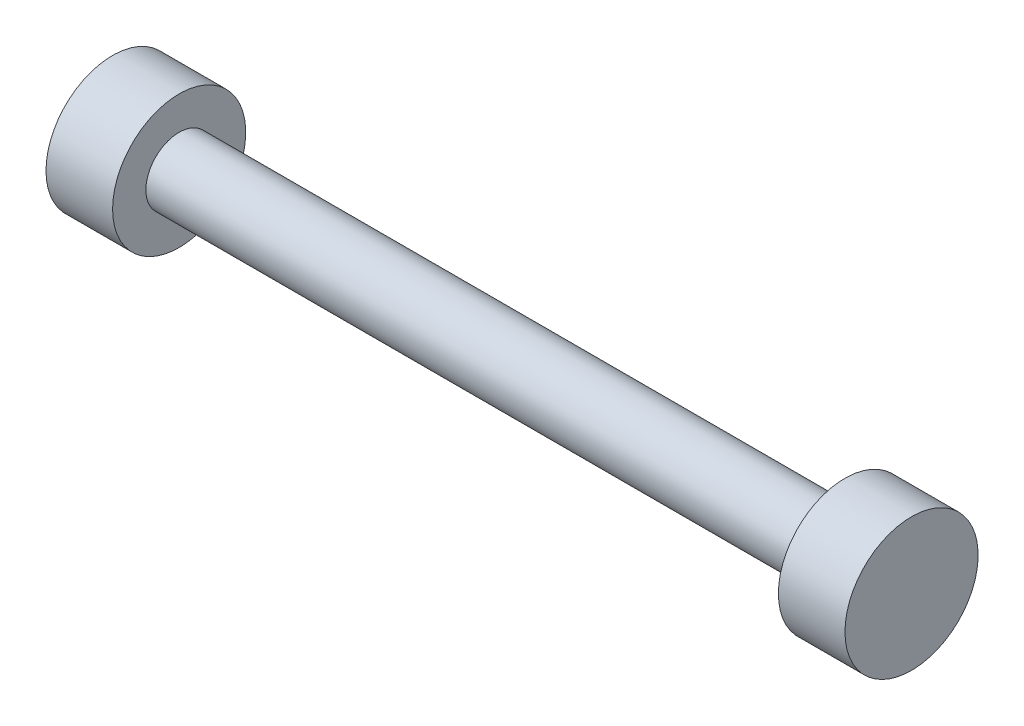
from build123d import *


with BuildPart() as part:
    # Croquis1 → Revolución1 (revolve)
    with BuildSketch(Plane(origin=(0, 0, 0), x_dir=(1, 0, 0), z_dir=(0, 1, 0))):
        Polygon((25, 2.5), (25, 5), (30, 5), (30, 0), (-30, 0), (-30, 5), (-25, 5), (-25, 2.5), align=None)
    revolve(axis=Axis((-39.502018508, 0, 0), (1, 0, 0)))


solid = part.part
